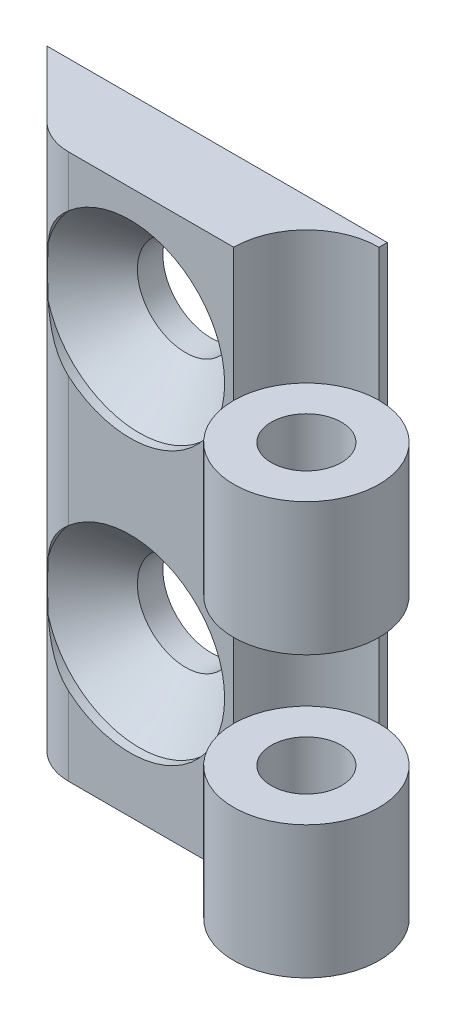
from build123d import *

# Parameters (mm, degrees)
SKETCH1_R                                    = 1.93
BOSS_EXTRUDE1_DEPTH                          = 7.3
BOSS_EXTRUDE2_DEPTH                          = 30
BOSS_EXTRUDE5_START                          = 15.4
SKETCH1_7_R                                  = 1.93
BOSS_EXTRUDE5_DEPTH                          = 7.3
CSK_FOR_M5_COUNTERSUNK_FLAT_HEAD_SCR_2_COUNT = 2
CSK_FOR_M5_COUNTERSUNK_FLAT_HEAD_SCR_2_PITCH = 15


with BuildPart() as part:
    # Sketch1 → Boss-Extrude1 (new body)
    with BuildSketch(Plane(origin=(0, 0, 0), x_dir=(1, 0, 0), z_dir=(0, 1, 0))):
        with BuildLine():
            Line((0, 4), (0, 4.45))
            Line((0, 4.45), (-18.73, 4.45))
            Line((-18.73, 4.45), (-15.127118856, 0.847118856))
            ThreePointArc((-15.127118856, 0.847118856), (-14.188807149, 0.220159018), (-13.081993025, 0))
            Line((-13.081993025, 0), (-4, 0))
            ThreePointArc((-4, 0), (2.828427125, -2.828427125), (0, 4))
        make_face()
        Circle(SKETCH1_R, mode=Mode.SUBTRACT)
    extrude(amount=BOSS_EXTRUDE1_DEPTH)

    # Sketch1_3 → Boss-Extrude2 (add)
    with BuildSketch(Plane(origin=(0, 0, 0), x_dir=(1, 0, 0), z_dir=(0, 1, 0))):
        with BuildLine():
            Line((0, 4), (0, 4.45))
            Line((0, 4.45), (-18.73, 4.45))
            Line((-18.73, 4.45), (-15.127118856, 0.847118856))
            ThreePointArc((-15.127118856, 0.847118856), (-14.188807149, 0.220159018), (-13.081993025, 0))
            Line((-13.081993025, 0), (-4, 0))
            ThreePointArc((-4, 0), (-2.828427125, 2.828427125), (0, 4))
        make_face()
    extrude(amount=BOSS_EXTRUDE2_DEPTH)

    # Sketch1_7 → Boss-Extrude5 (add)
    with BuildSketch(Plane(origin=(0, 0, 0), x_dir=(1, 0, 0), z_dir=(0, 1, 0)).offset(BOSS_EXTRUDE5_START)):
        with BuildLine():
            ThreePointArc((4, 0), (2.828427125, 2.828427125), (0, 4))
            ThreePointArc((0, 4), (-2.828427125, 2.828427125), (-4, 0))
            ThreePointArc((-4, 0), (0, -4), (4, 0))
        make_face()
        Circle(SKETCH1_7_R, mode=Mode.SUBTRACT)
    extrude(amount=BOSS_EXTRUDE5_DEPTH)

    # Sketch3 → CSK for M5 Countersunk Flat Head Screw1 (revolve, cut)
    with BuildSketch(Plane(origin=(-9.7, 23.25, 0), x_dir=(0, -1, 0), z_dir=(1, 0, 0))):
        Polygon((0, 0), (0, 4.45), (2.65, 4.45), (2.65, 3.05), (5.2, 0.5), (5.2, 0), align=None)
    csk_for_m5_countersunk_flat_head_screw1 = revolve(axis=Axis((-9.7, 23.25, 6.35), (0, 0, -1)), mode=Mode.SUBTRACT)

    # CSK for M5 Countersunk Flat Head Scr 2: CSK for M5 Countersunk Flat Head Screw1 ×2
    with Locations(*[(0, -i * CSK_FOR_M5_COUNTERSUNK_FLAT_HEAD_SCR_2_PITCH, 0) for i in range(1, CSK_FOR_M5_COUNTERSUNK_FLAT_HEAD_SCR_2_COUNT)]):
        add(csk_for_m5_countersunk_flat_head_screw1, mode=Mode.SUBTRACT)


solid = part.part
